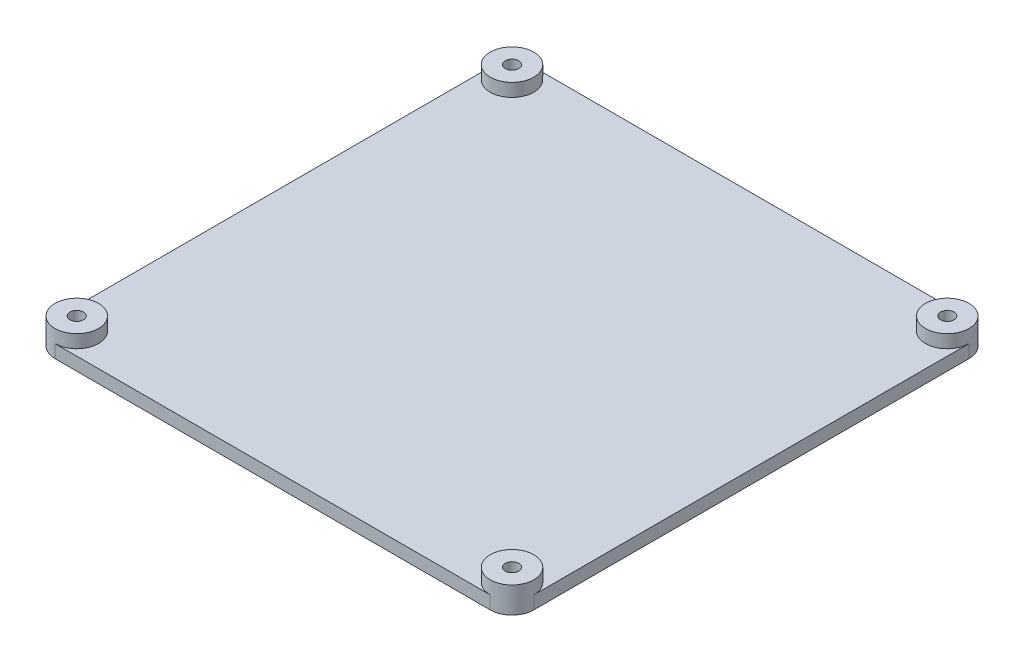
from build123d import *

# Parameters (mm, degrees)
SKETCH1_W           = 110
SKETCH1_H           = 110
BOSS_EXTRUDE1_DEPTH = 3
FILLET1_R           = 5
SKETCH2_R           = 5
BOSS_EXTRUDE2_DEPTH = 3
SKETCH6_R           = 1.55
CUT_EXTRUDE1_DEPTH  = 7


with BuildPart() as part:
    # Sketch1 → Boss-Extrude1 (new body)
    with BuildSketch(Plane(origin=(0, 0, 0), x_dir=(1, 0, 0), z_dir=(0, 1, 0))):
        Rectangle(SKETCH1_W, SKETCH1_H)
    extrude(amount=BOSS_EXTRUDE1_DEPTH)

    # Fillet1
    fillet1_edges = [part.edges().sort_by_distance(p)[0] for p in [
        (-55, 1.5, -55),
        (55, 1.5, -55),
        (55, 1.5, 55),
        (-55, 1.5, 55),
    ]]
    fillet(fillet1_edges, radius=FILLET1_R)

    # Sketch2 → Boss-Extrude2 (add)
    with BuildSketch(Plane(origin=(0, 3, 0), x_dir=(1, 0, 0), z_dir=(0, 1, 0))):
        with Locations((-50, 50)):
            Circle(SKETCH2_R)
        with Locations((50, 50)):
            Circle(SKETCH2_R)
        with Locations((50, -50)):
            Circle(SKETCH2_R)
        with Locations((-50, -50)):
            Circle(SKETCH2_R)
    extrude(amount=BOSS_EXTRUDE2_DEPTH)

    # Sketch6 → Cut-Extrude1 (cut, through all)
    with BuildSketch(Plane.XZ):
        with Locations((-50, 50)):
            Circle(SKETCH6_R)
        with Locations((50, -50)):
            Circle(SKETCH6_R)
        with Locations((50, 50)):
            Circle(SKETCH6_R)
        with Locations((-50, -50)):
            Circle(SKETCH6_R)
    extrude(amount=-CUT_EXTRUDE1_DEPTH, mode=Mode.SUBTRACT)


solid = part.part
